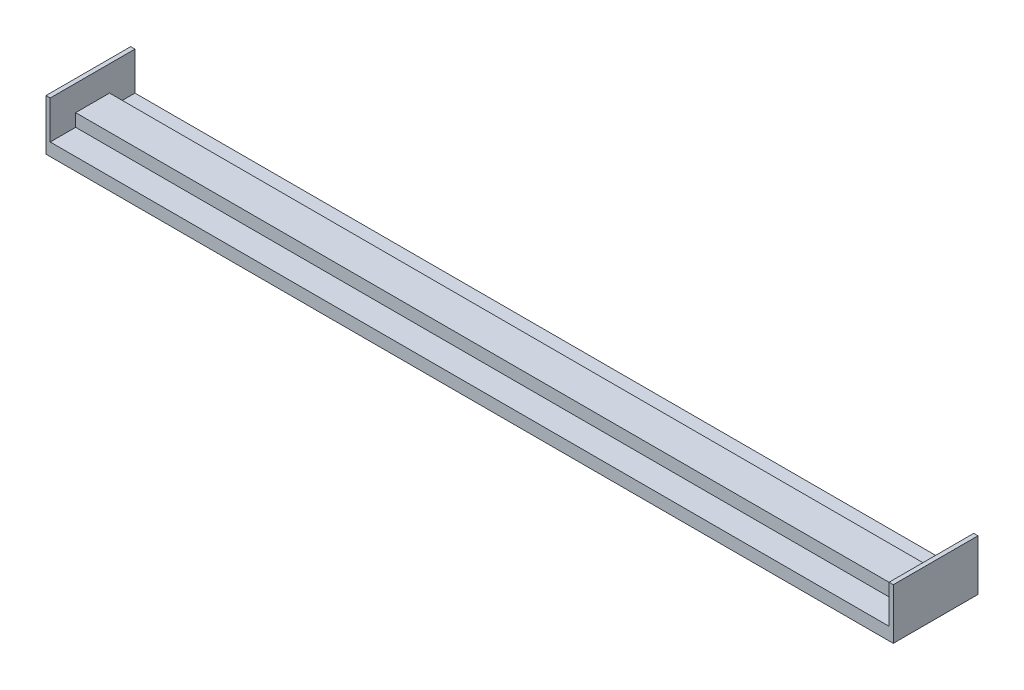
from build123d import *

# Parameters (mm, degrees)
SKETCH1_W           = 40
SKETCH1_H           = 15
BOSS_EXTRUDE1_DEPTH = 1000
SKETCH2_W           = 5
SKETCH2_H           = 60
BOSS_EXTRUDE2_DEPTH = 100


with BuildPart() as part:
    # Sketch1 → Boss-Extrude1 (new body)
    with BuildSketch(Plane(origin=(0, 0, 0), x_dir=(0, 0, -1), z_dir=(1, 0, 0))):
        Polygon((50, -7.5), (20, -7.5), (-20, -7.5), (-50, -7.5), (-50, -22.5), (50, -22.5), align=None)
        Rectangle(SKETCH1_W, SKETCH1_H)
    extrude(amount=-BOSS_EXTRUDE1_DEPTH)

    # Sketch2 → Boss-Extrude2 (add)
    with BuildSketch(Plane.XY.offset(50)):
        with Locations((-2.5, 7.5)):
            Rectangle(SKETCH2_W, SKETCH2_H)
    boss_extrude2 = extrude(amount=-BOSS_EXTRUDE2_DEPTH)

    # Mirror1: Boss-Extrude2 across plane
    add(boss_extrude2.mirror(Plane.ZY.offset(500)))


solid = part.part
